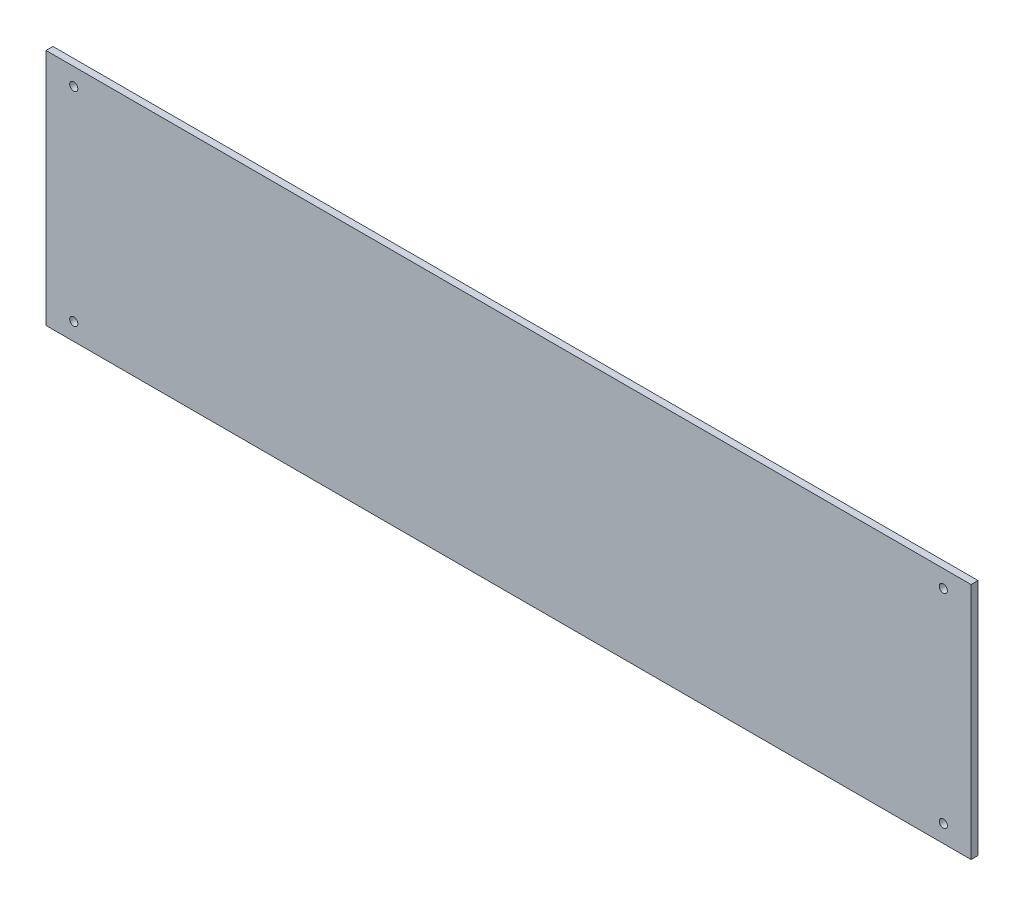
from build123d import *

# Parameters (mm, degrees)
SKETCH1_W           = 400
SKETCH1_H           = 100
BOSS_EXTRUDE1_DEPTH = 3
SKETCH7_R           = 1.75
CUT_EXTRUDE6_DEPTH  = 4
SKETCH8_W           = 400
SKETCH8_H           = 3
BOSS_EXTRUDE2_DEPTH = 3


with BuildPart() as part:
    # Sketch1 → Boss-Extrude1 (new body)
    with BuildSketch(Plane.XY):
        with Locations((200, 50)):
            Rectangle(SKETCH1_W, SKETCH1_H)
    extrude(amount=BOSS_EXTRUDE1_DEPTH)

    # Sketch7 → Cut-Extrude6 (cut, through all)
    with BuildSketch(Plane(origin=(0, 0, 0), x_dir=(-1, 0, 0), z_dir=(0, 0, -1))):
        with Locations((-388, 92.5)):
            Circle(SKETCH7_R)
        with Locations((-388, 4.5)):
            Circle(SKETCH7_R)
        with Locations((-12, 92.5)):
            Circle(SKETCH7_R)
        with Locations((-12, 4.5)):
            Circle(SKETCH7_R)
    extrude(amount=-CUT_EXTRUDE6_DEPTH, mode=Mode.SUBTRACT)

    # Sketch8 → Boss-Extrude2 (add)
    with BuildSketch(Plane(origin=(0, 0, 0), x_dir=(-1, 0, 0), z_dir=(0, -1, 0))):
        with Locations((-200, -1.5)):
            Rectangle(SKETCH8_W, SKETCH8_H)
    extrude(amount=BOSS_EXTRUDE2_DEPTH)


solid = part.part
